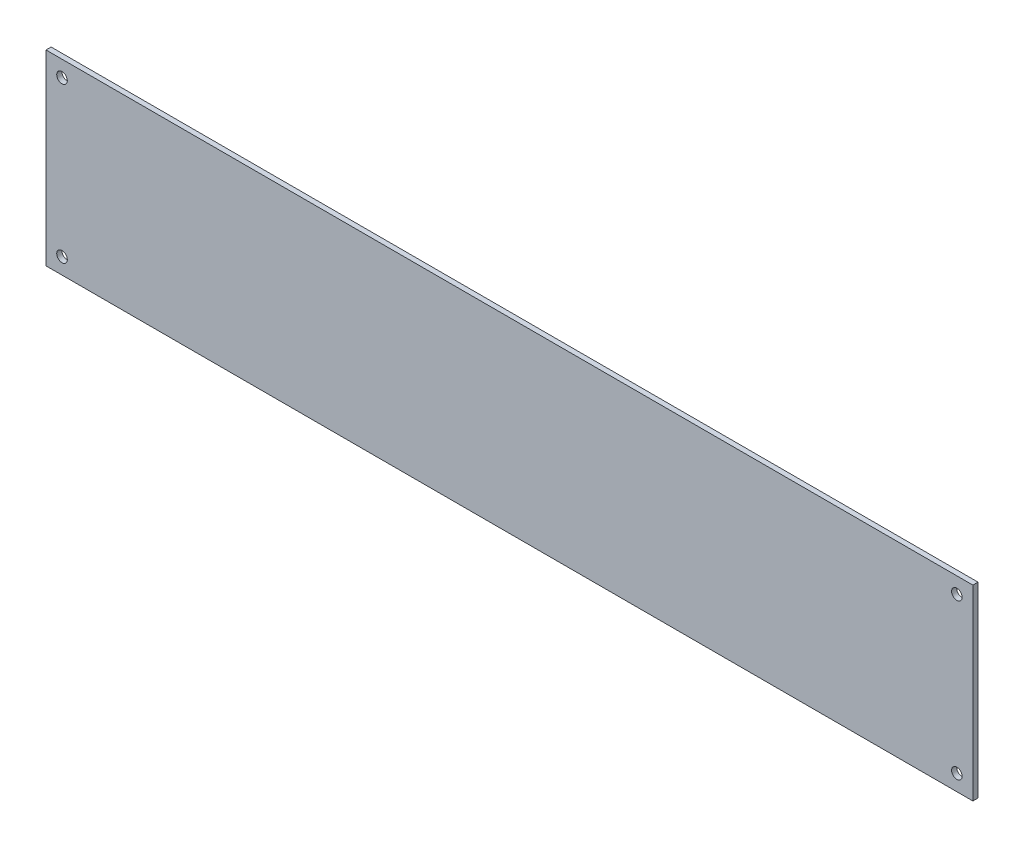
from build123d import *

# Parameters (mm, degrees)
SZKIC1_W                    = 289.561
SZKIC1_H                    = 58.42
SZKIC1_R                    = 1.65
DODANIE_WYCI_GNI_CIE1_DEPTH = 1.6


with BuildPart() as part:
    # Szkic1 → Dodanie-wyciągnięcie1 (new body)
    with BuildSketch(Plane.XY):
        with Locations((144.7805, 29.21)):
            Rectangle(SZKIC1_W, SZKIC1_H)
        with Locations((284.561, 5)):
            Circle(SZKIC1_R, mode=Mode.SUBTRACT)
        with Locations((284.561, 53.42)):
            Circle(SZKIC1_R, mode=Mode.SUBTRACT)
        with Locations((5, 53.42)):
            Circle(SZKIC1_R, mode=Mode.SUBTRACT)
        with Locations((5, 5)):
            Circle(SZKIC1_R, mode=Mode.SUBTRACT)
    extrude(amount=-DODANIE_WYCI_GNI_CIE1_DEPTH)


solid = part.part
